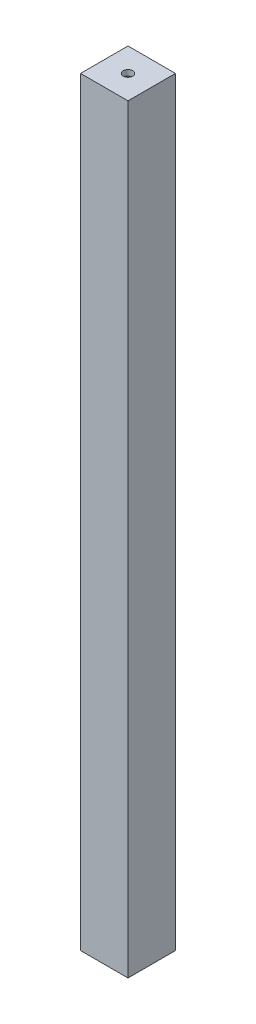
from build123d import *

# Parameters (mm, degrees)
SKETCH1_W           = 25
SKETCH1_H           = 25
BOSS_EXTRUDE1_DEPTH = 400
SHELL1_T            = -3
SKETCH2_W           = 19
SKETCH2_H           = 19
SKETCH2_R           = 2.5
BOSS_EXTRUDE2_DEPTH = 3


with BuildPart() as part:
    # Sketch1 → Boss-Extrude1 (new body)
    with BuildSketch(Plane(origin=(0, 0, 0), x_dir=(1, 0, 0), z_dir=(0, 1, 0))):
        Rectangle(SKETCH1_W, SKETCH1_H)
    extrude(amount=BOSS_EXTRUDE1_DEPTH)

    # Shell1
    shell1_openings = [part.faces().sort_by_distance(p)[0] for p in [
        (0, 400, 0),
        (0, 0, 0),
    ]]
    offset(amount=SHELL1_T, openings=shell1_openings, kind=Kind.INTERSECTION)

    # Sketch2 → Boss-Extrude2 (add)
    with BuildSketch(Plane(origin=(0, 400, 0), x_dir=(1, 0, 0), z_dir=(0, 1, 0))):
        Rectangle(SKETCH2_W, SKETCH2_H)
        Circle(SKETCH2_R, mode=Mode.SUBTRACT)
    extrude(amount=-BOSS_EXTRUDE2_DEPTH)


solid = part.part
